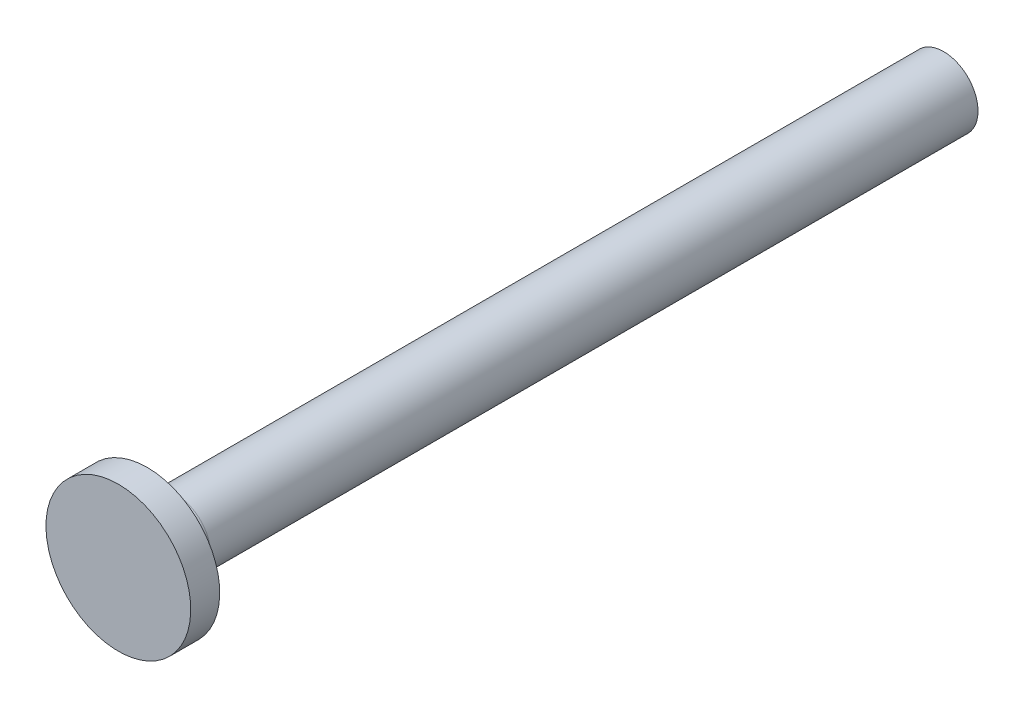
from build123d import *


with BuildPart() as part:
    # Sketch1 → Revolve1 (revolve)
    with BuildSketch(Plane.YZ):
        Polygon((0, -55), (0, 2), (-5, 2), (-5, 0), (-2.375, 0), (-2.375, -55), align=None)
    revolve(axis=Axis((0, 0, -55), (0, 0, 1)))


solid = part.part
